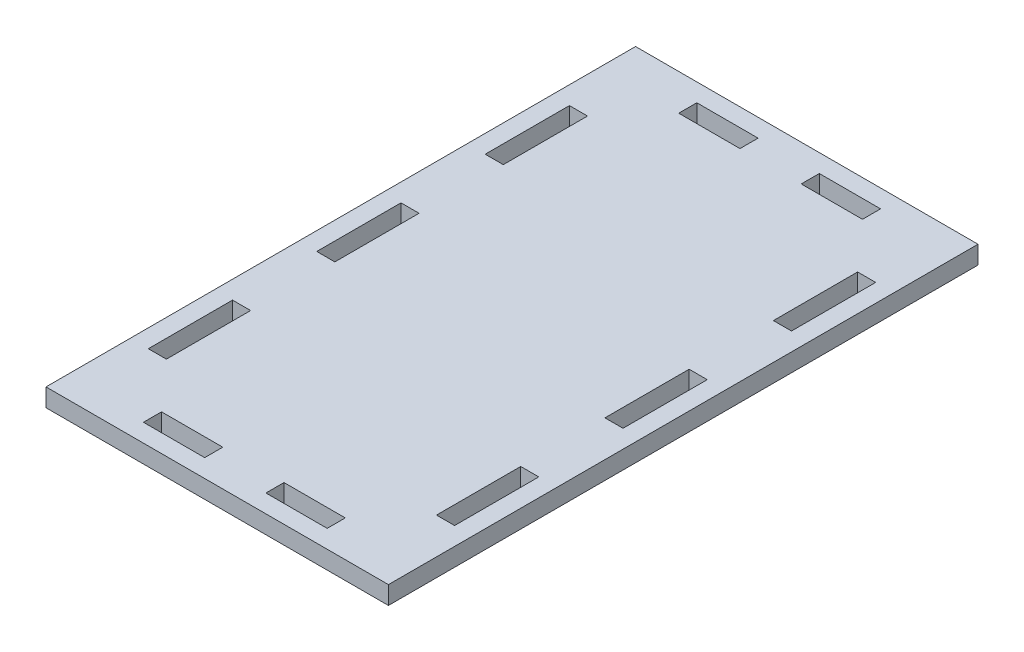
from build123d import *

# Parameters (mm, degrees)
SKETCH1_W           = 56.8
SKETCH1_H           = 97.79
BOSS_EXTRUDE1_DEPTH = 3
SKETCH2_W           = 10.16
SKETCH2_H           = 3
SKETCH2_W_2         = 3
SKETCH2_H_2         = 13.97
CUT_EXTRUDE1_DEPTH  = 4


with BuildPart() as part:
    # Sketch1 → Boss-Extrude1 (new body)
    with BuildSketch(Plane(origin=(0, 0, 0), x_dir=(1, 0, 0), z_dir=(0, 1, 0))):
        with Locations((28.4, 48.895)):
            Rectangle(SKETCH1_W, SKETCH1_H)
    extrude(amount=BOSS_EXTRUDE1_DEPTH)

    # Sketch2 → Cut-Extrude1 (cut, through all)
    with BuildSketch(Plane(origin=(0, 3, 0), x_dir=(1, 0, 0), z_dir=(0, 1, 0))):
        with Locations((18.24, 93.29)):
            Rectangle(SKETCH2_W, SKETCH2_H)
        with Locations((38.56, 93.29)):
            Rectangle(SKETCH2_W, SKETCH2_H)
        with Locations((52.3, 76.835)):
            Rectangle(SKETCH2_W_2, SKETCH2_H_2)
        with Locations((52.3, 48.895)):
            Rectangle(SKETCH2_W_2, SKETCH2_H_2)
        with Locations((52.3, 20.955)):
            Rectangle(SKETCH2_W_2, SKETCH2_H_2)
        with Locations((38.56, 4.5)):
            Rectangle(SKETCH2_W, SKETCH2_H)
        with Locations((18.24, 4.5)):
            Rectangle(SKETCH2_W, SKETCH2_H)
        with Locations((4.5, 76.835)):
            Rectangle(SKETCH2_W_2, SKETCH2_H_2)
        with Locations((4.5, 48.895)):
            Rectangle(SKETCH2_W_2, SKETCH2_H_2)
        with Locations((4.5, 20.955)):
            Rectangle(SKETCH2_W_2, SKETCH2_H_2)
    extrude(amount=-CUT_EXTRUDE1_DEPTH, mode=Mode.SUBTRACT)


solid = part.part
